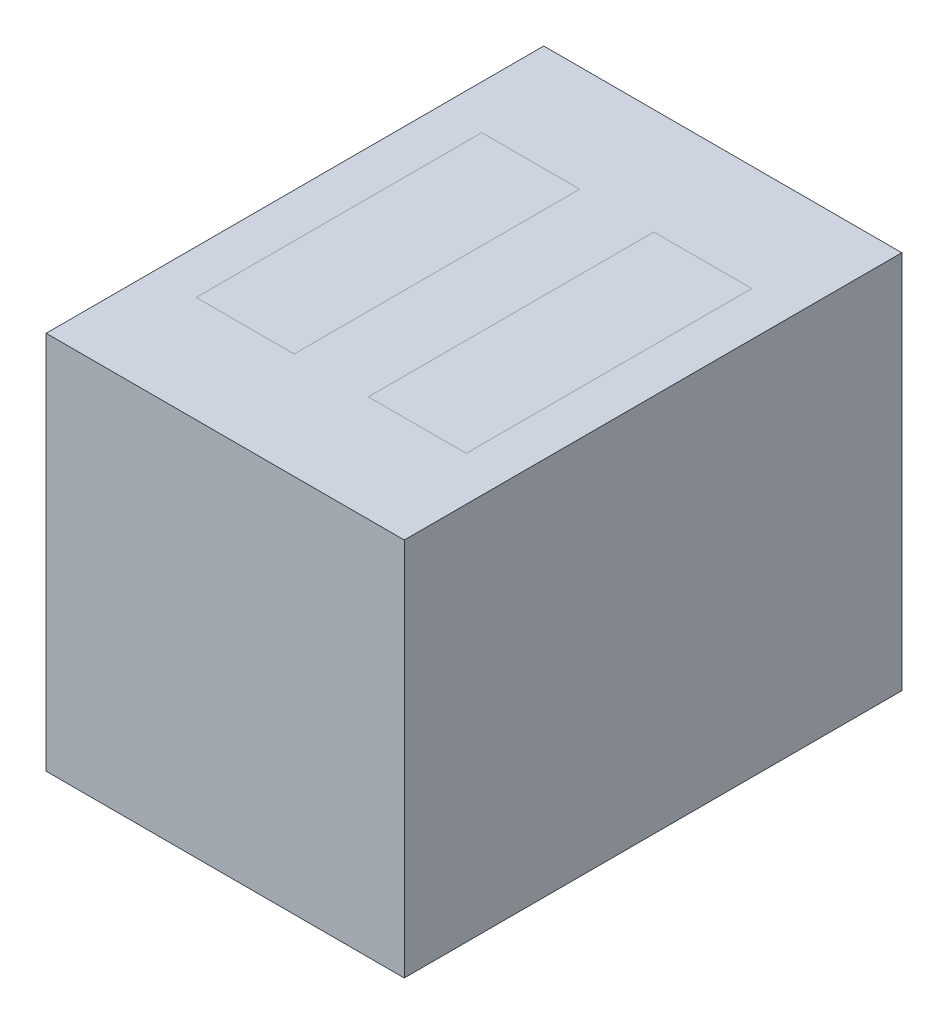
from build123d import *

# Parameters (mm, degrees)
SKETCH1_W             = 4.39
SKETCH1_H             = 6.1
BOSS_EXTRUDE1_DEPTH   = 4.65
SKETCH2_W             = 1.2
SKETCH2_H             = 3.5
CUT_EXTRUDE1_DEPTH    = 2
SKETCH2_3_W           = 1.2
SKETCH2_3_H           = 3.5
BOSS_EXTRUDE2_DEPTH   = 2
BOSS_EXTRUDE2_2_DEPTH = 2


with BuildPart() as part:
    # Sketch1 → Boss-Extrude1 (new body)
    with BuildSketch(Plane(origin=(0, 0, 0), x_dir=(1, 0, 0), z_dir=(0, 1, 0))):
        with Locations((2.195, 3.05)):
            Rectangle(SKETCH1_W, SKETCH1_H)
    extrude(amount=BOSS_EXTRUDE1_DEPTH)

    # Sketch2 → Cut-Extrude1 (cut)
    with BuildSketch(Plane(origin=(0, 4.65, 0), x_dir=(1, 0, 0), z_dir=(0, 1, 0))):
        with Locations((1.14, 3.05)):
            Rectangle(SKETCH2_W, SKETCH2_H)
        with Locations((3.25, 3.05)):
            Rectangle(SKETCH2_W, SKETCH2_H)
    extrude(amount=-CUT_EXTRUDE1_DEPTH, mode=Mode.SUBTRACT)


with BuildPart() as body_2:
    # Sketch2_3 → Boss-Extrude2 (new body)
    with BuildSketch(Plane(origin=(0, 4.65, 0), x_dir=(1, 0, 0), z_dir=(0, 1, 0))):
        with Locations((1.14, 3.05)):
            Rectangle(SKETCH2_3_W, SKETCH2_3_H)
    extrude(amount=-BOSS_EXTRUDE2_DEPTH)


with BuildPart() as body_3:
    # Sketch2_3 → Boss-Extrude2 2 (new body)
    with BuildSketch(Plane(origin=(0, 4.65, 0), x_dir=(1, 0, 0), z_dir=(0, 1, 0))):
        with Locations((3.25, 3.05)):
            Rectangle(SKETCH2_3_W, SKETCH2_3_H)
    extrude(amount=-BOSS_EXTRUDE2_2_DEPTH)


solid = Compound([part.part, body_2.part, body_3.part])
